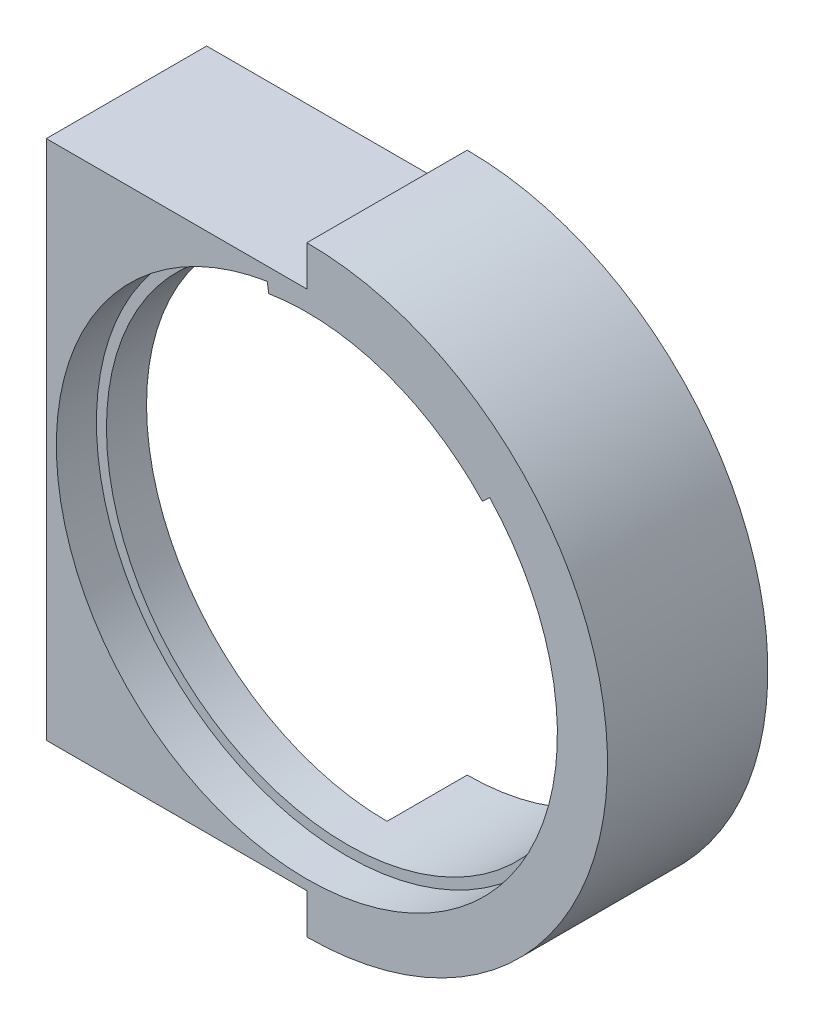
from build123d import *

# Parameters (mm, degrees)
SKETCH1_R           = 38.1
BOSS_EXTRUDE1_DEPTH = 25.4
CUT_EXTRUDE1_DEPTH  = 6.35
CUT_EXTRUDE2_START  = -12.7
CUT_EXTRUDE2_DEPTH  = 12.7


with BuildPart() as part:
    # Sketch1 → Boss-Extrude1 (new body)
    with BuildSketch(Plane.XY):
        with BuildLine():
            Line((-41.275, -41.275), (-41.275, 41.275))
            Line((-41.275, 41.275), (0, 41.275))
            Line((0, 41.275), (0, 47.625))
            ThreePointArc((0, 47.625), (47.625, 0), (0, -47.625))
            Line((0, -47.625), (0, -41.275))
            Line((0, -41.275), (-41.275, -41.275))
        make_face()
        Circle(SKETCH1_R, mode=Mode.SUBTRACT)
    extrude(amount=BOSS_EXTRUDE1_DEPTH)

    # Sketch5 → Cut-Revolve3 (revolve, cut)
    with BuildSketch(Plane(origin=(0, 0, 12.7), x_dir=(-1, 0, 0), z_dir=(0, 0, -1))):
        with BuildLine():
            Line((0.422989948, -1.197488832), (-13.958668291, 39.517131469))
            ThreePointArc((-13.958668291, 39.517131469), (-27.125149322, 11.968992199), (0.422989948, -1.197488832))
        make_face()
    revolve(axis=Axis((-0.422989948, -1.197488832, 12.7), (0.333062951, 0.942904592, 0)), mode=Mode.SUBTRACT)

    # Sketch2 → Cut-Extrude1 (cut)
    with BuildSketch(Plane.XY.offset(25.4)):
        with BuildLine():
            Line((-6.286105585, 39.186509577), (0, 0))
            Line((0, 0), (28.956627522, 27.140585455))
            ThreePointArc((28.956627522, 27.140585455), (-12.836051309, -37.55440644), (-6.286105585, 39.186509577))
        make_face()
    extrude(amount=-CUT_EXTRUDE1_DEPTH, mode=Mode.SUBTRACT)

    # Sketch4 → Cut-Extrude2 (cut)
    with BuildSketch(Plane(origin=(0, 0, 0), x_dir=(-1, 0, 0), z_dir=(0, 0, -1)).offset(CUT_EXTRUDE2_START)):
        with BuildLine():
            Line((0, 38.1), (0, -41.275))
            Line((0, -41.275), (41.275, -41.275))
            Line((41.275, -41.275), (41.275, 41.275))
            ThreePointArc((41.275, 41.275), (20.706704521, 38.787841223), (0, 38.1))
        make_face()
    extrude(amount=CUT_EXTRUDE2_DEPTH, mode=Mode.SUBTRACT)


solid = part.part
